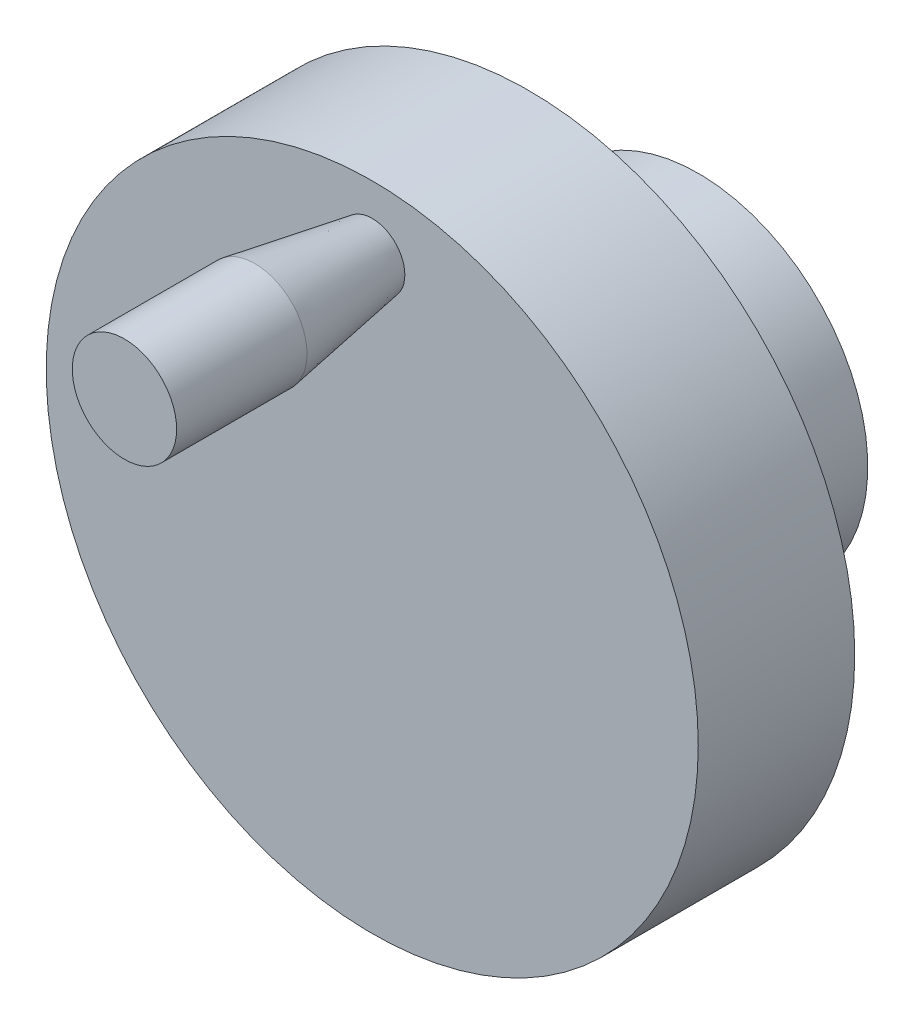
from build123d import *

# Parameters (mm, degrees)
SKETCH_1_R          = 25
EXTRUDE_1_DEPTH     = 12
SKETCH_2_R          = 13
EXTRUDE_2_DEPTH     = 13
SKETCH_3_R          = 4
CUT_EXTRUDE_1_DEPTH = 13


with BuildPart() as part:
    # 草图1 → 凸台-拉伸1 (new body)
    with BuildSketch(Plane.XY):
        Circle(SKETCH_1_R)
    extrude(amount=EXTRUDE_1_DEPTH)

    # 草图2 → 凸台-拉伸2 (add)
    with BuildSketch(Plane(origin=(0, 0, 0), x_dir=(-1, 0, 0), z_dir=(0, 0, -1))):
        Circle(SKETCH_2_R)
    extrude(amount=EXTRUDE_2_DEPTH)

    # 草图3 → 切除-拉伸1 (cut)
    with BuildSketch(Plane(origin=(0, 0, -13), x_dir=(-1, 0, 0), z_dir=(0, 0, -1))):
        Circle(SKETCH_3_R)
    extrude(amount=-CUT_EXTRUDE_1_DEPTH, mode=Mode.SUBTRACT)

    # 草图4 → 旋转1 (revolve)
    with BuildSketch(Plane(origin=(0, 0, 0), x_dir=(0, 0, -1), z_dir=(1, 0, 0))):
        Polygon((-12, 22.5), (-21, 24), (-31, 24), (-31, 20), (-12, 20), align=None)
    revolve(axis=Axis((0, 20, 31), (0, 0, -1)))


solid = part.part
